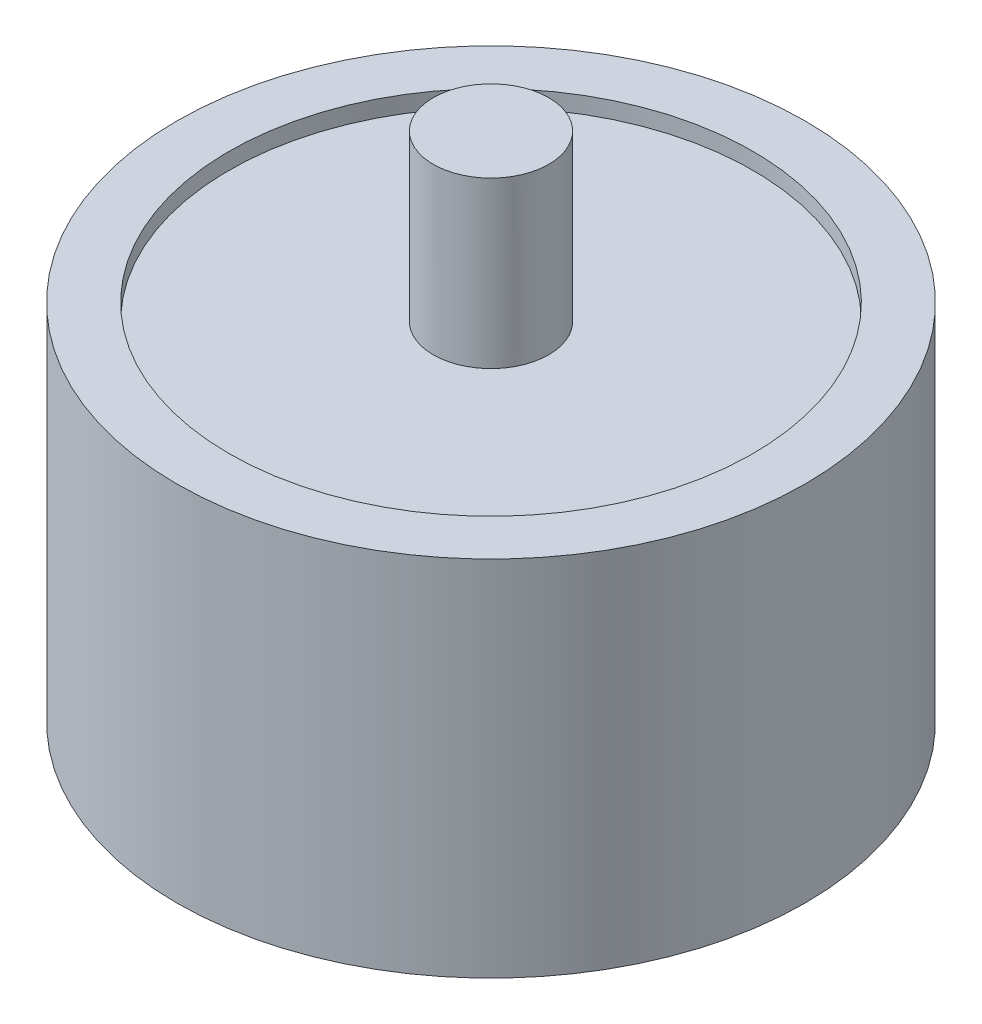
from build123d import *

# Parameters (mm, degrees)
SKETCH1_R                = 15.875
BOSS_EXTRUDE1_DEPTH      = 20
SKETCH2_R                = 3.5
BOSS_EXTRUDE2_DEPTH      = 10
BOSS_EXTRUDE2_DEPTH_BACK = 30
SKETCH3_R                = 19.05
SKETCH3_R_2              = 15.875
BOSS_EXTRUDE3_DEPTH      = 21
BOSS_EXTRUDE3_DEPTH_BACK = 1


with BuildPart() as part:
    # Sketch1 → Boss-Extrude1 (new body)
    with BuildSketch(Plane(origin=(0, 0, 0), x_dir=(1, 0, 0), z_dir=(0, 1, 0))):
        Circle(SKETCH1_R)
    extrude(amount=BOSS_EXTRUDE1_DEPTH)

    # Sketch2 → Boss-Extrude2 (add, two sides)
    with BuildSketch(Plane.XZ) as boss_extrude2_sk:
        Circle(SKETCH2_R)
    extrude(amount=BOSS_EXTRUDE2_DEPTH)
    extrude(boss_extrude2_sk.sketch, amount=-BOSS_EXTRUDE2_DEPTH_BACK)

    # Sketch3 → Boss-Extrude3 (add, two sides)
    with BuildSketch(Plane(origin=(0, 0, 0), x_dir=(1, 0, 0), z_dir=(0, 1, 0))) as boss_extrude3_sk:
        Circle(SKETCH3_R)
        Circle(SKETCH3_R_2, mode=Mode.SUBTRACT)
    extrude(amount=BOSS_EXTRUDE3_DEPTH)
    extrude(boss_extrude3_sk.sketch, amount=-BOSS_EXTRUDE3_DEPTH_BACK)


solid = part.part
